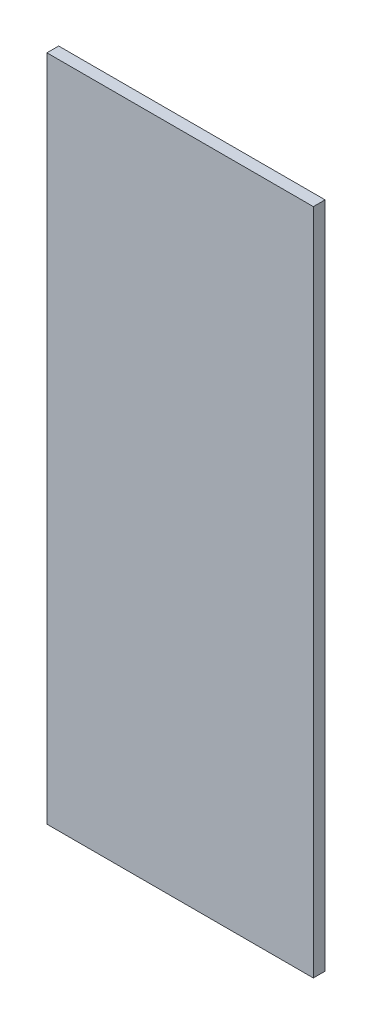
from build123d import *

# Parameters (mm, degrees)
SKETCH1_W           = 408
SKETCH1_H           = 1023
BOSS_EXTRUDE1_DEPTH = 18


with BuildPart() as part:
    # Sketch1 → Boss-Extrude1 (new body)
    with BuildSketch(Plane.XY):
        Rectangle(SKETCH1_W, SKETCH1_H)
    extrude(amount=BOSS_EXTRUDE1_DEPTH)


solid = part.part
